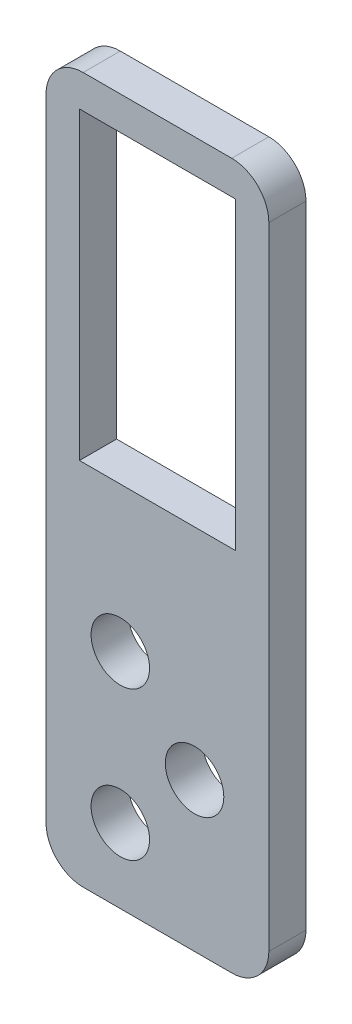
from build123d import *

# Parameters (mm, degrees)
SKETCH1_W           = 26.67
SKETCH1_H           = 52.07
BOSS_EXTRUDE1_DEPTH = 6.35
FILLET1_R           = 6.35


with BuildPart() as part:
    # Sketch1 → Boss-Extrude1 (new body)
    with BuildSketch(Plane.XY):
        with BuildLine():
            Line((12.7, -63.5), (0, -63.5))
            Line((0, -63.5), (0, -120.671250195))
            Line((0, -120.671250195), (12.7, -120.671250195))
            Line((12.7, -120.671250195), (12.7, -112.971250195))
            ThreePointArc((12.7, -112.971250195), (7.7, -107.971250195), (12.7, -102.971250195))
            Line((12.7, -102.971250195), (12.7, -87.571250195))
            ThreePointArc((12.7, -87.571250195), (7.7, -82.571250195), (12.7, -77.571250195))
            Line((12.7, -77.571250195), (12.7, -63.5))
        make_face()
        with BuildLine():
            Line((25.4, -63.5), (12.7, -63.5))
            Line((12.7, -63.5), (12.7, -77.571250195))
            ThreePointArc((12.7, -77.571250195), (16.235533906, -79.035716289), (17.7, -82.571250195))
            ThreePointArc((17.7, -82.571250195), (16.235533906, -86.106784101), (12.7, -87.571250195))
            Line((12.7, -87.571250195), (12.7, -102.971250195))
            ThreePointArc((12.7, -102.971250195), (16.235533906, -104.435716289), (17.7, -107.971250195))
            ThreePointArc((17.7, -107.971250195), (16.235533906, -111.506784101), (12.7, -112.971250195))
            Line((12.7, -112.971250195), (12.7, -120.671250195))
            Line((12.7, -120.671250195), (25.4, -120.671250195))
            Line((25.4, -120.671250195), (25.4, -100.271250195))
            ThreePointArc((25.4, -100.271250195), (20.4, -95.271250195), (25.4, -90.271250195))
            Line((25.4, -90.271250195), (25.4, -63.5))
        make_face()
        with BuildLine():
            Line((38.1, -120.671250195), (38.1, -63.5))
            Line((38.1, -63.5), (25.4, -63.5))
            Line((25.4, -63.5), (25.4, -90.271250195))
            ThreePointArc((25.4, -90.271250195), (28.935533906, -91.735716289), (30.4, -95.271250195))
            ThreePointArc((30.4, -95.271250195), (28.935533906, -98.806784101), (25.4, -100.271250195))
            Line((25.4, -100.271250195), (25.4, -120.671250195))
            Line((25.4, -120.671250195), (38.1, -120.671250195))
        make_face()
        Polygon((38.1, 0), (0, 0), (0, -63.5), (12.7, -63.5), (25.4, -63.5), (38.1, -63.5), align=None)
        with Locations((19.05, -31.75)):
            Rectangle(SKETCH1_W, SKETCH1_H, mode=Mode.SUBTRACT)
    extrude(amount=BOSS_EXTRUDE1_DEPTH)

    # Fillet1
    fillet1_edges = [part.edges().sort_by_distance(p)[0] for p in [
        (0, -120.671250195, 3.175),
        (0, 0, 3.175),
        (38.1, 0, 3.175),
        (38.1, -120.671250195, 3.175),
    ]]
    fillet(fillet1_edges, radius=FILLET1_R)


solid = part.part
